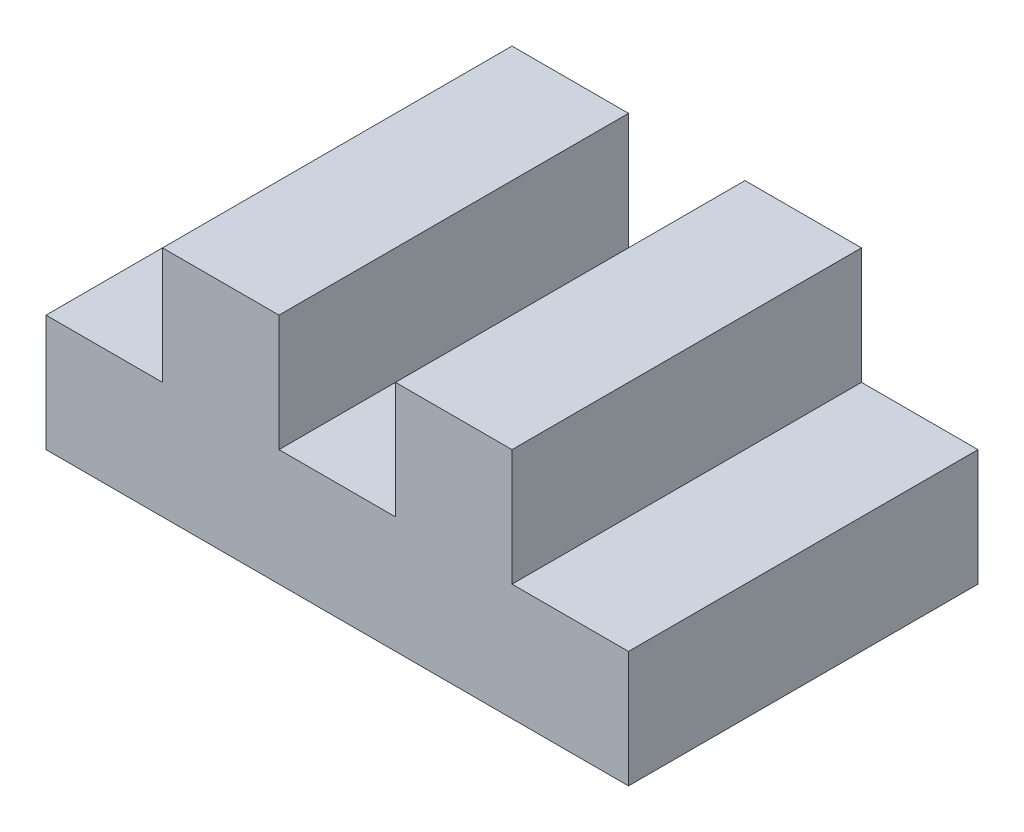
from build123d import *

# Parameters (mm, degrees)
BOSS_EXTRUDE1_DEPTH = 30


with BuildPart() as part:
    # Sketch2 → Boss-Extrude1 (new body)
    with BuildSketch(Plane.XY):
        Polygon((0, 0), (50, 0), (50, 10), (40, 10), (40, 20), (30, 20), (30, 10), (20, 10), (20, 20), (10, 20), (10, 10), (0, 10), align=None)
    extrude(amount=BOSS_EXTRUDE1_DEPTH)


solid = part.part
